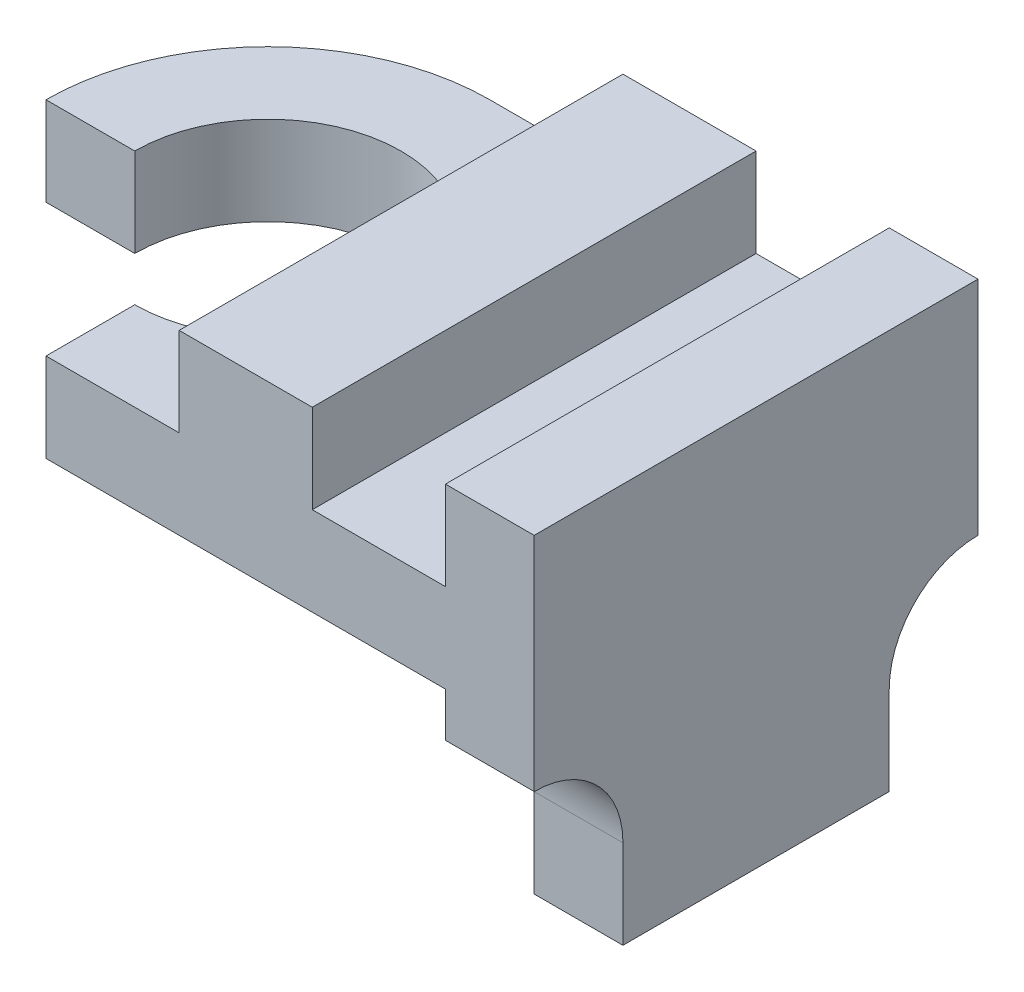
from build123d import *

# Parameters (mm, degrees)
SKETCH2_W           = 110
SKETCH2_H           = 40
BOSS_EXTRUDE1_DEPTH = 100
SKETCH3_W           = 30
SKETCH3_H           = 20
CUT_EXTRUDE1_DEPTH  = 100
SKETCH4_W           = 20
SKETCH4_H           = 100
BOSS_EXTRUDE3_DEPTH = 50
CUT_EXTRUDE2_DEPTH  = 50
SKETCH7_W           = 40
SKETCH7_H           = 20
BOSS_EXTRUDE4_DEPTH = 30
CUT_EXTRUDE3_DEPTH  = 30
SKETCH9_W           = 50
SKETCH9_H           = 50
BOSS_EXTRUDE5_DEPTH = 20
CUT_EXTRUDE5_DEPTH  = 20
CUT_EXTRUDE6_DEPTH  = 20


with BuildPart() as part:
    # Sketch2 → Boss-Extrude1 (new body)
    with BuildSketch(Plane.XY):
        with Locations((55, 20)):
            Rectangle(SKETCH2_W, SKETCH2_H)
    extrude(amount=BOSS_EXTRUDE1_DEPTH)

    # Sketch3 → Cut-Extrude1 (cut)
    with BuildSketch(Plane.XY.offset(100)):
        with Locations((75, 30)):
            Rectangle(SKETCH3_W, SKETCH3_H)
        with Locations((15, 30)):
            Rectangle(SKETCH3_W, SKETCH3_H)
    extrude(amount=-CUT_EXTRUDE1_DEPTH, mode=Mode.SUBTRACT)

    # Sketch4 → Boss-Extrude3 (add)
    with BuildSketch(Plane(origin=(0, 0, 0), x_dir=(-1, 0, 0), z_dir=(0, -1, 0))):
        with Locations((-100, -50)):
            Rectangle(SKETCH4_W, SKETCH4_H)
    extrude(amount=BOSS_EXTRUDE3_DEPTH)

    # Sketch6 → Cut-Extrude2 (cut)
    with BuildSketch(Plane.ZY.offset(-90)):
        with BuildLine():
            Line((80, -30), (80, -50))
            Line((80, -50), (100, -50))
            Line((100, -50), (100, -10))
            ThreePointArc((100, -10), (85.857864376, -15.857864376), (80, -30))
        make_face()
        with BuildLine():
            Line((20, -30), (20, -50))
            Line((20, -50), (0, -50))
            Line((0, -50), (0, -10))
            ThreePointArc((0, -10), (14.142135624, -15.857864376), (20, -30))
        make_face()
    extrude(amount=-CUT_EXTRUDE2_DEPTH, mode=Mode.SUBTRACT)

    # Sketch7 → Boss-Extrude4 (add)
    with BuildSketch(Plane(origin=(0, 0, 0), x_dir=(-1, 0, 0), z_dir=(0, -1, 0))):
        with Locations((-70, -50)):
            Rectangle(SKETCH7_W, SKETCH7_H)
    extrude(amount=BOSS_EXTRUDE4_DEPTH)

    # Sketch8 → Cut-Extrude3 (cut)
    with BuildSketch(Plane.XY.offset(60)):
        Polygon((90, -30), (50, 0), (50, -30), align=None)
    extrude(amount=-CUT_EXTRUDE3_DEPTH, mode=Mode.SUBTRACT)

    # Sketch9 → Boss-Extrude5 (add)
    with BuildSketch(Plane(origin=(0, 0, 0), x_dir=(-1, 0, 0), z_dir=(0, -1, 0))):
        with Locations((25, -25)):
            Rectangle(SKETCH9_W, SKETCH9_H)
    extrude(amount=-BOSS_EXTRUDE5_DEPTH)

    # Sketch10 → Cut-Extrude5 (cut)
    with BuildSketch(Plane(origin=(0, 0, 0), x_dir=(-1, 0, 0), z_dir=(0, -1, 0))):
        with BuildLine():
            Line((30, -50), (0, -50))
            Line((0, -50), (0, -80))
            ThreePointArc((0, -80), (-21.213203436, -28.786796564), (30, -50))
        make_face()
    extrude(amount=-CUT_EXTRUDE5_DEPTH, mode=Mode.SUBTRACT)

    # Sketch12 → Cut-Extrude6 (cut)
    with BuildSketch(Plane(origin=(0, 0, 0), x_dir=(-1, 0, 0), z_dir=(0, -1, 0))):
        with BuildLine():
            Line((50, -50), (50, 0))
            Line((50, 0), (0, 0))
            ThreePointArc((0, 0), (35.355339059, -14.644660941), (50, -50))
        make_face()
    extrude(amount=-CUT_EXTRUDE6_DEPTH, mode=Mode.SUBTRACT)


solid = part.part
